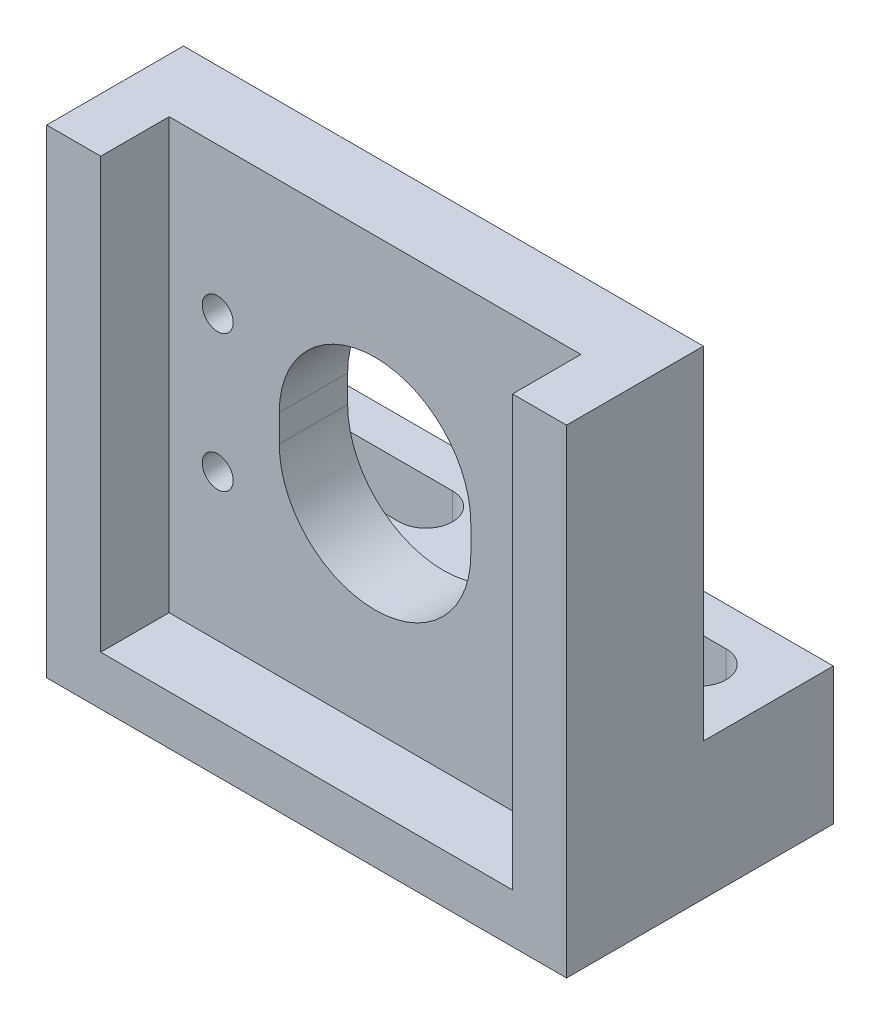
from build123d import *

# Parameters (mm, degrees)
SKETCH1_W                = 38
SKETCH1_H                = 19.5
BOSS_EXTRUDE1_DEPTH      = 35
SKETCH2_W                = 38
SKETCH2_H                = 9.5
CUT_EXTRUDE1_DEPTH       = 25
F_6_32_SLOT_REACH        = 12
APERTURE_THRU_HOLE_REACH = 21.5
SKETCH5_4_R              = 1.13
CUT_EXTRUDE5_DEPTH       = 5
F_4_40_TAPPED_HOLE1_D    = 2.2606


with BuildPart() as part:
    # Sketch1 → Boss-Extrude1 (new body)
    with BuildSketch(Plane(origin=(0, 0, 0), x_dir=(1, 0, 0), z_dir=(0, 1, 0))):
        with Locations((-7.223776224, 34.305944056)):
            Rectangle(SKETCH1_W, SKETCH1_H)
    extrude(amount=BOSS_EXTRUDE1_DEPTH)

    # Sketch2 → Cut-Extrude1 (cut)
    with BuildSketch(Plane(origin=(0, 35, 0), x_dir=(1, 0, 0), z_dir=(0, 1, 0))):
        with Locations((-7.223776224, 39.305944056)):
            Rectangle(SKETCH2_W, SKETCH2_H)
    extrude(amount=-CUT_EXTRUDE1_DEPTH, mode=Mode.SUBTRACT)

    # Sketch4 → 6-32 slot (cut, up to next)
    with BuildSketch(Plane(origin=(0, 10, 0), x_dir=(1, 0, 0), z_dir=(0, 1, 0)), mode=Mode.PRIVATE) as f_6_32_slot_sk1:
        with BuildLine():
            ThreePointArc((-13.223776224, 41.225951608), (-11.268776224, 39.270951608), (-13.223776224, 37.315951608))
            Line((-13.223776224, 37.315951608), (-21.223776224, 37.315951608))
            ThreePointArc((-21.223776224, 37.315951608), (-23.178776224, 39.270951608), (-21.223776224, 41.225951608))
            Line((-21.223776224, 41.225951608), (-13.223776224, 41.225951608))
        make_face()
    f_6_32_slot_tool1 = extrude(f_6_32_slot_sk1.sketch, amount=-F_6_32_SLOT_REACH, mode=Mode.PRIVATE) & part.part
    add(f_6_32_slot_tool1.solids().sort_by_distance((-17.223776, 10, -39.270952))[0], mode=Mode.SUBTRACT)
    # Sketch4 → 6-32 slot (cut, up to next)
    with BuildSketch(Plane(origin=(0, 10, 0), x_dir=(1, 0, 0), z_dir=(0, 1, 0)), mode=Mode.PRIVATE) as f_6_32_slot_sk2:
        with BuildLine():
            Line((6.776223776, 41.225951608), (-1.223776224, 41.225951608))
            ThreePointArc((-1.223776224, 41.225951608), (-3.178776224, 39.270951608), (-1.223776224, 37.315951608))
            Line((-1.223776224, 37.315951608), (6.776223776, 37.315951608))
            ThreePointArc((6.776223776, 37.315951608), (8.731223776, 39.270951608), (6.776223776, 41.225951608))
        make_face()
    f_6_32_slot_tool2 = extrude(f_6_32_slot_sk2.sketch, amount=-F_6_32_SLOT_REACH, mode=Mode.PRIVATE) & part.part
    add(f_6_32_slot_tool2.solids().sort_by_distance((2.776224, 10, -39.270952))[0], mode=Mode.SUBTRACT)

    # Sketch5 → aperture thru hole (cut, up to next)
    with BuildSketch(Plane.XY.offset(-24.555944056), mode=Mode.PRIVATE) as aperture_thru_hole_sk1:
        with BuildLine():
            Line((-14.223776224, 18.3), (-14.223776224, 20.3))
            ThreePointArc((-14.223776224, 20.3), (-7.223776224, 27.3), (-0.223776224, 20.3))
            Line((-0.223776224, 20.3), (-0.223776224, 18.3))
            ThreePointArc((-0.223776224, 18.3), (-7.223776224, 11.3), (-14.223776224, 18.3))
        make_face()
    aperture_thru_hole_tool1 = extrude(aperture_thru_hole_sk1.sketch, amount=-APERTURE_THRU_HOLE_REACH, mode=Mode.PRIVATE) & part.part
    add(aperture_thru_hole_tool1.solids().sort_by_distance((-7.223776, 19.3, -24.555944))[0], mode=Mode.SUBTRACT)

    # Sketch5_4 → Cut-Extrude5 (cut)
    with BuildSketch(Plane.XY.offset(-24.555944056)):
        with BuildLine():
            Line((-7.223776224, 27.3), (-7.223776224, 35))
            Line((-7.223776224, 35), (-22.273776224, 35))
            Line((-22.273776224, 35), (-22.273776224, 19.3))
            Line((-22.273776224, 19.3), (-14.223776224, 19.3))
            Line((-14.223776224, 19.3), (-14.223776224, 20.3))
            ThreePointArc((-14.223776224, 20.3), (-12.173523692, 25.249747468), (-7.223776224, 27.3))
        make_face()
        with Locations((-18.723776224, 24.3)):
            Circle(SKETCH5_4_R, mode=Mode.SUBTRACT)
        with BuildLine():
            Line((7.826223776, 35), (-7.223776224, 35))
            Line((-7.223776224, 35), (-7.223776224, 27.3))
            ThreePointArc((-7.223776224, 27.3), (-2.274028755, 25.249747468), (-0.223776224, 20.3))
            Line((-0.223776224, 20.3), (-0.223776224, 19.3))
            Line((-0.223776224, 19.3), (7.826223776, 19.3))
            Line((7.826223776, 19.3), (7.826223776, 35))
        make_face()
        with Locations((4.276223776, 24.3)):
            Circle(SKETCH5_4_R, mode=Mode.SUBTRACT)
        with BuildLine():
            Line((7.826223776, 3.6), (7.826223776, 19.3))
            Line((7.826223776, 19.3), (-0.223776224, 19.3))
            Line((-0.223776224, 19.3), (-0.223776224, 18.3))
            ThreePointArc((-0.223776224, 18.3), (-2.274028755, 13.350252532), (-7.223776224, 11.3))
            Line((-7.223776224, 11.3), (-7.223776224, 3.6))
            Line((-7.223776224, 3.6), (7.826223776, 3.6))
        make_face()
        with Locations((4.276223776, 14.3)):
            Circle(SKETCH5_4_R, mode=Mode.SUBTRACT)
        with BuildLine():
            Line((-14.223776224, 19.3), (-22.273776224, 19.3))
            Line((-22.273776224, 19.3), (-22.273776224, 3.6))
            Line((-22.273776224, 3.6), (-7.223776224, 3.6))
            Line((-7.223776224, 3.6), (-7.223776224, 11.3))
            ThreePointArc((-7.223776224, 11.3), (-12.173523692, 13.350252532), (-14.223776224, 18.3))
            Line((-14.223776224, 18.3), (-14.223776224, 19.3))
        make_face()
        with Locations((-18.723776224, 14.3)):
            Circle(SKETCH5_4_R, mode=Mode.SUBTRACT)
    extrude(amount=-CUT_EXTRUDE5_DEPTH, mode=Mode.SUBTRACT)

    # 4-40 Tapped Hole1 (through all)
    with Locations(Plane.XY.offset(-24.555944056)):
        with Locations((-18.723776224, 24.3), (-18.723776224, 14.3), (4.276223776, 14.3), (4.276223776, 24.3)):
            Hole(F_4_40_TAPPED_HOLE1_D / 2)


solid = part.part
